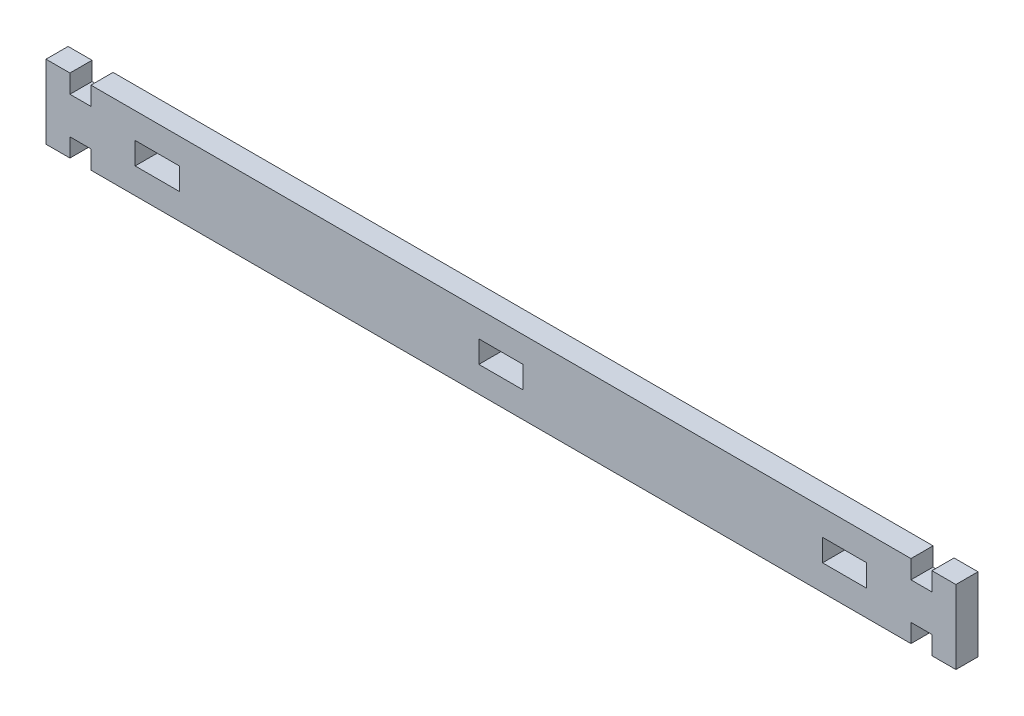
from build123d import *

# Parameters (mm, degrees)
SKETCH1_W           = 12
SKETCH1_H           = 6
BOSS_EXTRUDE1_DEPTH = 6


with BuildPart() as part:
    # Sketch1 → Boss-Extrude1 (new body)
    with BuildSketch(Plane.XY):
        Polygon((-123.5, 10), (-123.5, -10), (-117, -10), (-117, -5), (-111.3, -5), (-111.3, -10), (111.3, -10), (111.3, -5), (117, -5), (117, -10), (123.5, -10), (123.5, 10), (117, 10), (117, 5), (111.3, 5), (111.3, 10), (-111.3, 10), (-111.3, 5), (-117, 5), (-117, 10), align=None)
        with Locations((93.3, 0)):
            Rectangle(SKETCH1_W, SKETCH1_H, mode=Mode.SUBTRACT)
        with Locations((-93.3, 0)):
            Rectangle(SKETCH1_W, SKETCH1_H, mode=Mode.SUBTRACT)
        Rectangle(SKETCH1_W, SKETCH1_H, mode=Mode.SUBTRACT)
    extrude(amount=-BOSS_EXTRUDE1_DEPTH)


solid = part.part
